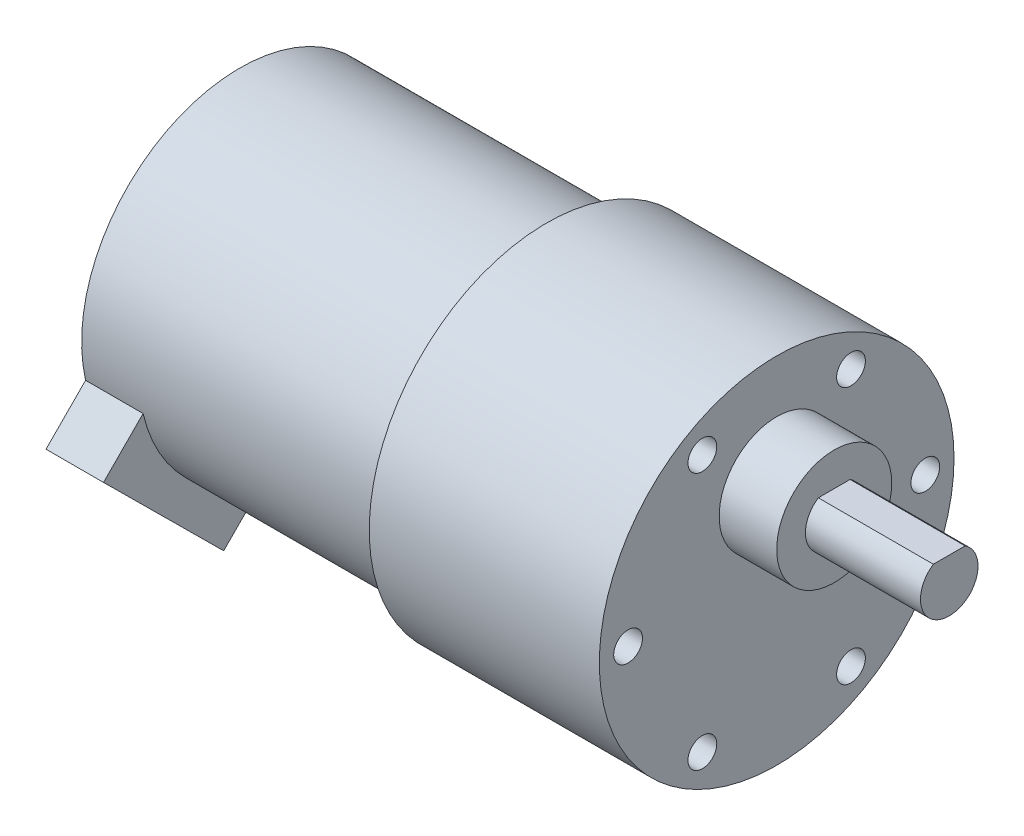
from build123d import *

# Parameters (mm, degrees)
SKETCH_1_R          = 18.5
EXTRUDE_1_DEPTH     = 24
SKETCH_2_R          = 16.5
EXTRUDE_2_DEPTH     = 32
SKETCH_4_R          = 1.5
CUT_EXTRUDE_1_DEPTH = 6
SKETCH_5_R          = 6
EXTRUDE_3_DEPTH     = 6
EXTRUDE_4_DEPTH     = 12
EXTRUDE_5_DEPTH     = 6


with BuildPart() as part:
    # 草图1 → 凸台-拉伸1 (new body)
    with BuildSketch(Plane(origin=(0, 0, 0), x_dir=(0, 0, -1), z_dir=(1, 0, 0))):
        Circle(SKETCH_1_R)
    extrude(amount=EXTRUDE_1_DEPTH)

    # 草图2 → 凸台-拉伸2 (add)
    with BuildSketch(Plane.ZY):
        Circle(SKETCH_2_R)
    extrude(amount=EXTRUDE_2_DEPTH)

    # 草图4 → 切除-拉伸1 (cut)
    with BuildSketch(Plane(origin=(24, 0, 0), x_dir=(0, 0, -1), z_dir=(1, 0, 0))):
        with Locations((15.5, 0)):
            Circle(SKETCH_4_R)
        with Locations((7.75, -13.423393759)):
            Circle(SKETCH_4_R)
        with Locations((-7.75, -13.423393759)):
            Circle(SKETCH_4_R)
        with Locations((-15.5, 0)):
            Circle(SKETCH_4_R)
        with Locations((-7.75, 13.423393759)):
            Circle(SKETCH_4_R)
        with Locations((7.75, 13.423393759)):
            Circle(SKETCH_4_R)
    extrude(amount=-CUT_EXTRUDE_1_DEPTH, mode=Mode.SUBTRACT)

    # 草图5 → 凸台-拉伸3 (add)
    with BuildSketch(Plane(origin=(24, 0, 0), x_dir=(0, 0, -1), z_dir=(1, 0, 0))):
        with Locations((0, 7)):
            Circle(SKETCH_5_R)
    extrude(amount=EXTRUDE_3_DEPTH)

    # 草图6 → 凸台-拉伸4 (add)
    with BuildSketch(Plane(origin=(30, 0, 0), x_dir=(0, 0, -1), z_dir=(1, 0, 0))):
        with BuildLine():
            Line((-1.658312395, 9.5), (1.658312395, 9.5))
            ThreePointArc((1.658312395, 9.5), (0, 4), (-1.658312395, 9.5))
        make_face()
    extrude(amount=EXTRUDE_4_DEPTH)

    # 草图7 → 凸台-拉伸5 (add)
    with BuildSketch(Plane.ZY.offset(32)):
        Polygon((7.680859807, -20.274157757), (20.216755747, -7.8307003), (16.086686091, -3.669949673), (3.550790151, -16.113407129), align=None)
    extrude(amount=-EXTRUDE_5_DEPTH)


solid = part.part
